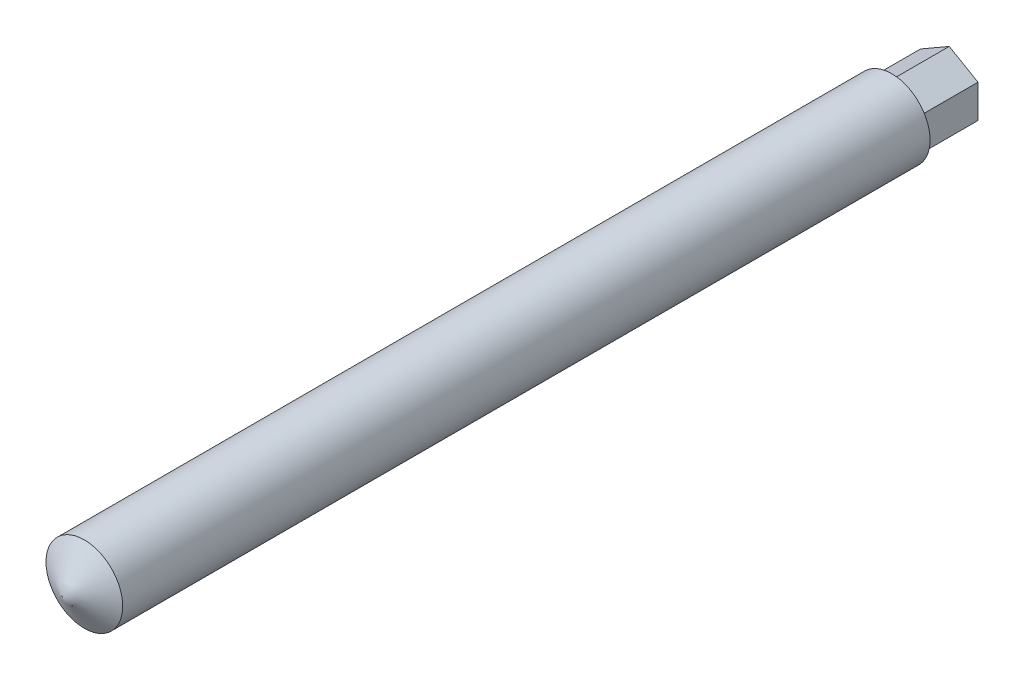
from build123d import *

# Parameters (mm, degrees)
EXTRUDE_1_DEPTH = 15


with BuildPart() as part:
    # Эскиз1 → Повернуть1 (revolve)
    with BuildSketch(Plane(origin=(0, 0, 0), x_dir=(0, 0, -1), z_dir=(1, 0, 0))):
        Polygon((-176.350852961, 0), (40, 0), (40, 10), (-170.577350269, 10), align=None)
    revolve(axis=Axis((0, 0, 756.580802456), (0, 0, -1)))

    # Эскиз4 → Бобышка-Вытянуть1 (add)
    with BuildSketch(Plane(origin=(0, 0, -40), x_dir=(-1, 0, 0), z_dir=(0, 0, -1))):
        Polygon((0, 8.660254038), (-7.5, 4.330127019), (-7.5, -4.330127019), (0, -8.660254038), (7.5, -4.330127019), (7.5, 4.330127019), align=None)
    extrude(amount=EXTRUDE_1_DEPTH)


solid = part.part
